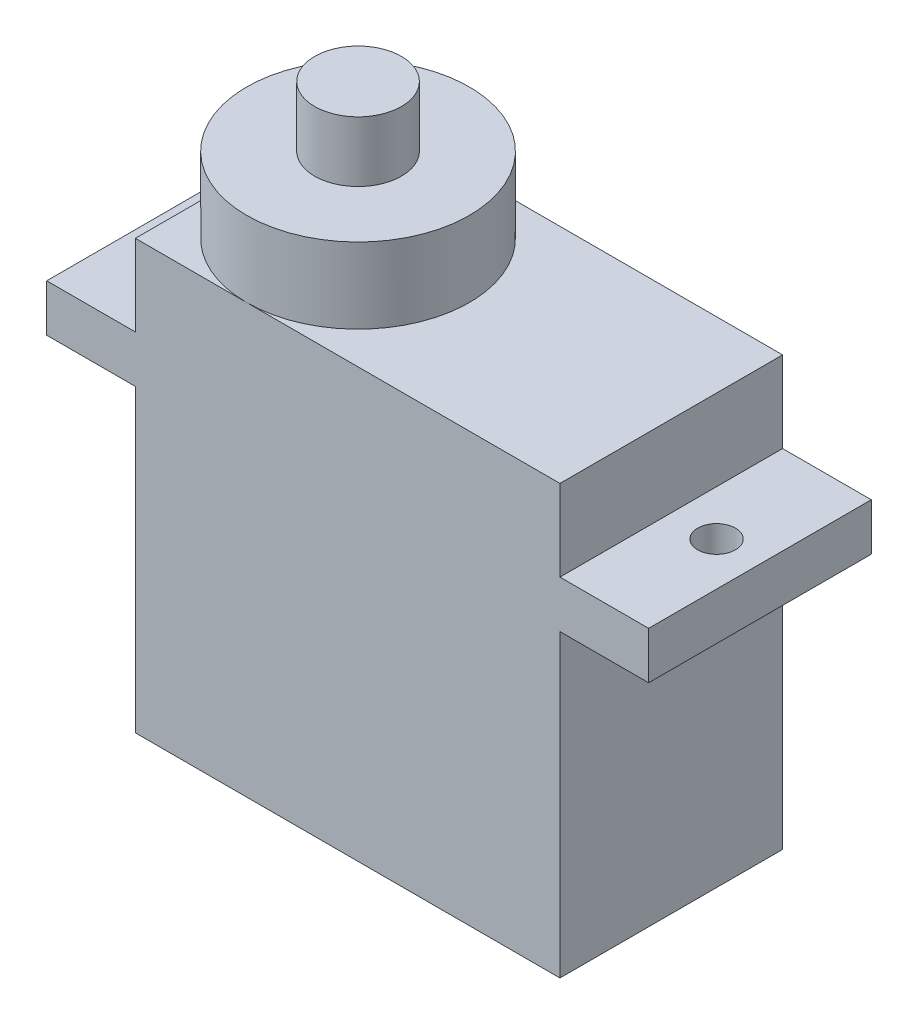
from build123d import *

# Parameters (mm, degrees)
SKETCH1_W           = 4.7
SKETCH1_H           = 2.5
SKETCH1_W_2         = 22.5
SKETCH1_H_2         = 22.7
BOSS_EXTRUDE1_DEPTH = 11.8
SKETCH3_R           = 5.9
BOSS_EXTRUDE2_DEPTH = 4
BOSS_EXTRUDE3_DEPTH = 3.2
SKETCH6_R           = 1
CUT_EXTRUDE1_DEPTH  = 10


with BuildPart() as part:
    # Sketch1 → Boss-Extrude1 (new body)
    with BuildSketch(Plane.XY):
        with Locations((24.85, 17.15)):
            Rectangle(SKETCH1_W, SKETCH1_H)
        with Locations((11.25, 11.35)):
            Rectangle(SKETCH1_W_2, SKETCH1_H_2)
        with Locations((-2.35, 17.15)):
            Rectangle(SKETCH1_W, SKETCH1_H)
    extrude(amount=BOSS_EXTRUDE1_DEPTH)

    # Sketch3 → Boss-Extrude2 (add)
    with BuildSketch(Plane(origin=(0, 22.7, 0), x_dir=(1, 0, 0), z_dir=(0, 1, 0))):
        with Locations((5.9, -5.9)):
            Circle(SKETCH3_R)
    extrude(amount=BOSS_EXTRUDE2_DEPTH)

    # Sketch5 → Boss-Extrude3 (add)
    with BuildSketch(Plane(origin=(0, 26.7, 0), x_dir=(1, 0, 0), z_dir=(0, 1, 0))):
        with BuildLine():
            ThreePointArc((8.2, -5.9), (5.9, -3.6), (3.6, -5.9))
            Line((3.6, -5.9), (8.2, -5.9))
        make_face()
        with BuildLine():
            Line((8.2, -5.9), (3.6, -5.9))
            ThreePointArc((3.6, -5.9), (5.9, -8.2), (8.2, -5.9))
        make_face()
    extrude(amount=BOSS_EXTRUDE3_DEPTH)

    # Sketch6 → Cut-Extrude1 (cut)
    with BuildSketch(Plane(origin=(0, 18.4, 0), x_dir=(1, 0, 0), z_dir=(0, 1, 0))):
        with Locations((24.9, -5.9)):
            Circle(SKETCH6_R)
        with Locations((-2.4, -5.9)):
            Circle(SKETCH6_R)
    extrude(amount=-CUT_EXTRUDE1_DEPTH, mode=Mode.SUBTRACT)


solid = part.part
